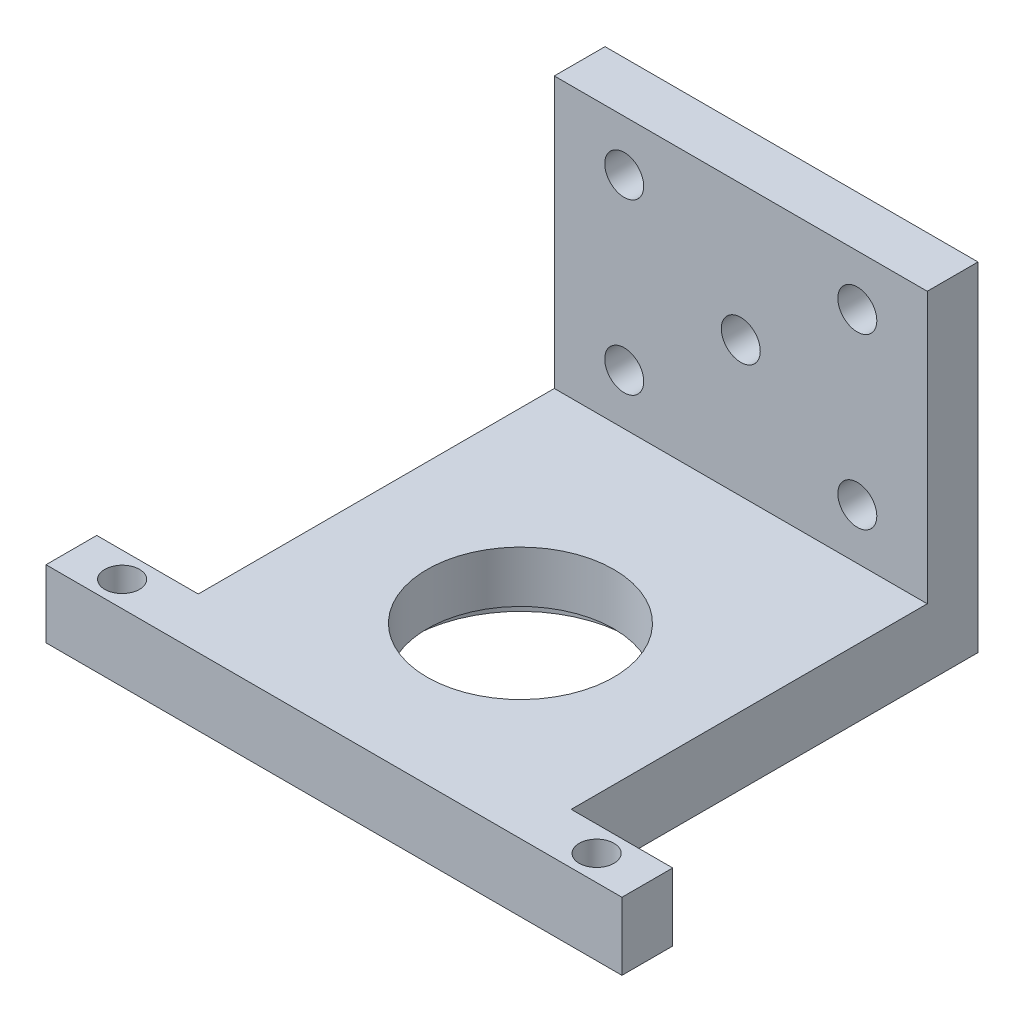
from build123d import *

# Parameters (mm, degrees)
SKETCH1_W                 = 35
SKETCH1_H                 = 42.9375
BOSS_EXTRUDE1_DEPTH       = 6.35
SKETCH2_W                 = 35
SKETCH2_H                 = 4.7625
BOSS_EXTRUDE2_DEPTH       = 25.4
SKETCH3_R                 = 8.763
CUT_EXTRUDE1_DEPTH        = 32.75
F_6_CLEARANCE_HOLE1_D     = 3.6576
SKETCH13_R                = 10.3505
SKETCH13_R_2              = 8.763
CUT_EXTRUDE2_DEPTH        = 1.524
SKETCH14_W                = 9.525
SKETCH14_H                = 4.7625
BOSS_EXTRUDE4_DEPTH       = 6.35
F_4_CLEARANCE_HOLE1_D     = 3.2639
F_4_CLEARANCE_HOLE1_DEPTH = 10.16
F_4_CLEARANCE_HOLE1_TIP   = 0.980574487


with BuildPart() as part:
    # Sketch1 → Boss-Extrude1 (new body)
    with BuildSketch(Plane(origin=(0, 0, 0), x_dir=(1, 0, 0), z_dir=(0, 1, 0))):
        with Locations((17.5, 21.46875)):
            Rectangle(SKETCH1_W, SKETCH1_H)
    extrude(amount=BOSS_EXTRUDE1_DEPTH)

    # Sketch2 → Boss-Extrude2 (add)
    with BuildSketch(Plane(origin=(0, 6.35, 0), x_dir=(1, 0, 0), z_dir=(0, 1, 0))):
        with Locations((17.5, 40.55625)):
            Rectangle(SKETCH2_W, SKETCH2_H)
    extrude(amount=BOSS_EXTRUDE2_DEPTH)

    # Sketch3 → Cut-Extrude1 (cut, through all)
    with BuildSketch(Plane.XZ):
        with Locations((17.5, -17.5)):
            Circle(SKETCH3_R)
    extrude(amount=-CUT_EXTRUDE1_DEPTH, mode=Mode.SUBTRACT)

    # #6 Clearance Hole1 (through all)
    with Locations(Plane.XY.offset(-38.175)):
        with Locations((6.5625, 26.9875), (17.5, 19.05), (6.5625, 11.1125), (28.4375, 26.9875), (28.4375, 11.1125)):
            Hole(F_6_CLEARANCE_HOLE1_D / 2)

    # Sketch13 → Cut-Extrude2 (cut)
    with BuildSketch(Plane.XZ):
        with Locations((17.5, -17.5)):
            Circle(SKETCH13_R)
        with Locations((17.5, -17.5)):
            Circle(SKETCH13_R_2, mode=Mode.SUBTRACT)
    extrude(amount=-CUT_EXTRUDE2_DEPTH, mode=Mode.SUBTRACT)

    # Sketch14 → Boss-Extrude4 (add)
    with BuildSketch(Plane.XZ):
        with Locations((39.7625, -2.38125)):
            Rectangle(SKETCH14_W, SKETCH14_H)
        with Locations((-4.7625, -2.38125)):
            Rectangle(SKETCH14_W, SKETCH14_H)
    extrude(amount=-BOSS_EXTRUDE4_DEPTH)

    # #4 Clearance Hole1
    with Locations(Plane(origin=(0, 0, 0), x_dir=(-1, 0, 0), z_dir=(0, -1, 0))):
        with Locations((4.7625, 2.38125), (-39.7625, 2.38125)):
            Hole(F_4_CLEARANCE_HOLE1_D / 2, depth=F_4_CLEARANCE_HOLE1_DEPTH)
            with Locations((0, 0, -(F_4_CLEARANCE_HOLE1_DEPTH + F_4_CLEARANCE_HOLE1_TIP / 2))):  # 118° drill point
                Cone(0, F_4_CLEARANCE_HOLE1_D / 2, F_4_CLEARANCE_HOLE1_TIP, mode=Mode.SUBTRACT)


solid = part.part
